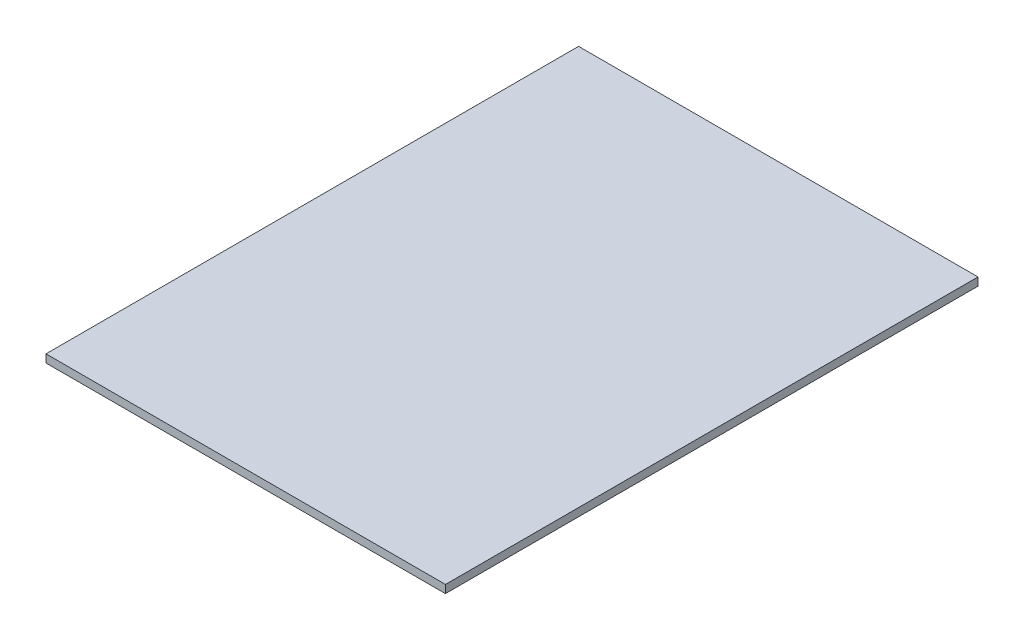
from build123d import *

# Parameters (mm, degrees)
SKETCH5_W           = 150
SKETCH5_H           = 200
BOSS_EXTRUDE1_DEPTH = 3


with BuildPart() as part:
    # Sketch5 → Boss-Extrude1 (new body)
    with BuildSketch(Plane(origin=(0, 0, 0), x_dir=(1, 0, 0), z_dir=(0, 1, 0))):
        Rectangle(SKETCH5_W, SKETCH5_H)
    extrude(amount=BOSS_EXTRUDE1_DEPTH)


solid = part.part
